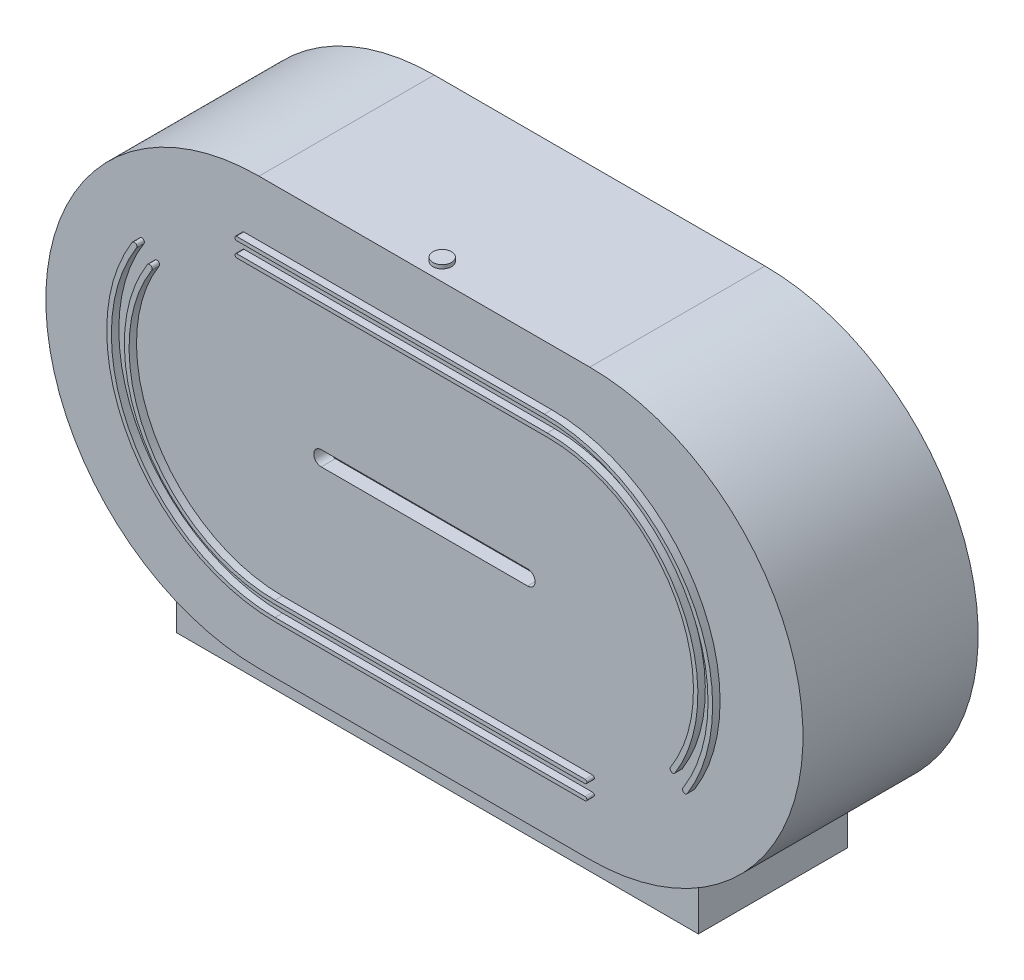
from build123d import *

# Parameters (mm, degrees)
BOSS_EXTRUDE1_DEPTH = 119.38
SKETCH2_W           = 355.6
SKETCH2_H           = 101.6
BOSS_EXTRUDE2_DEPTH = 44.958
CUT_EXTRUDE1_DEPTH  = 9.652
SKETCH4_R           = 6.35
BOSS_EXTRUDE3_DEPTH = 2.54
BOSS_EXTRUDE4_DEPTH = 5.08


with BuildPart() as part:
    # Sketch1 → Boss-Extrude1 (new body)
    with BuildSketch(Plane.XY):
        with BuildLine():
            Line((-76.285439921, 56.800521538), (149.139560079, 56.800521538))
            ThreePointArc((149.139560079, 56.800521538), (294.427560079, -88.487478462), (149.139560079, -233.775478462))
            Line((149.139560079, -233.775478462), (-76.285439921, -233.775478462))
            ThreePointArc((-76.285439921, -233.775478462), (-221.573439921, -88.487478462), (-76.285439921, 56.800521538))
        make_face()
    extrude(amount=BOSS_EXTRUDE1_DEPTH)

    # Sketch2 → Boss-Extrude2 (add)
    with BuildSketch(Plane(origin=(0, -249.650478462, 0), x_dir=(-1, 0, 0), z_dir=(0, -1, 0))):
        with Locations((-36.427060079, -59.69)):
            Rectangle(SKETCH2_W, SKETCH2_H)
    extrude(amount=-BOSS_EXTRUDE2_DEPTH)

    # Sketch3 → Cut-Extrude1 (cut)
    with BuildSketch(Plane.XY.offset(119.38)):
        with BuildLine():
            Line((-33.895177701, -83.407478462), (106.749297859, -83.407478462))
            ThreePointArc((106.749297859, -83.407478462), (111.829297859, -88.487478462), (106.749297859, -93.567478462))
            Line((106.749297859, -93.567478462), (-33.895177701, -93.567478462))
            ThreePointArc((-33.895177701, -93.567478462), (-38.975177701, -88.487478462), (-33.895177701, -83.407478462))
        make_face()
    extrude(amount=-CUT_EXTRUDE1_DEPTH, mode=Mode.SUBTRACT)

    # Sketch4 → Boss-Extrude3 (add)
    with BuildSketch(Plane(origin=(0, 56.800521538, 0), x_dir=(1, 0, 0), z_dir=(0, 1, 0))):
        with Locations((36.427060079, -107.228428284)):
            Circle(SKETCH4_R)
    extrude(amount=BOSS_EXTRUDE3_DEPTH)

    # Sketch5 → Boss-Extrude4 (add)
    with BuildSketch(Plane.XY.offset(119.38)):
        with BuildLine():
            Line((-86.479093302, 18.700521538), (123.251136742, 18.700521538))
            ThreePointArc((123.251136742, 18.700521538), (223.504350955, -40.293834211), (220.612604828, -156.580887552))
            ThreePointArc((220.612604828, -156.580887552), (218.022957646, -157.022271916), (217.893868774, -154.398452419))
            ThreePointArc((217.893868774, -154.398452419), (220.780120028, -41.258888911), (123.251136742, 16.160521538))
            Line((123.251136742, 16.160521538), (-86.479093302, 16.160521538))
            ThreePointArc((-86.479093302, 16.160521538), (-87.749093302, 17.430521538), (-86.479093302, 18.700521538))
        make_face()
        with BuildLine():
            Line((-86.313359517, 8.540521538), (125.193739137, 8.540521538))
            ThreePointArc((125.193739137, 8.540521538), (215.020934696, -44.395432513), (212.23038132, -148.622843039))
            ThreePointArc((212.23038132, -148.622843039), (209.771349214, -149.194111608), (209.219629388, -146.730619796))
            ThreePointArc((209.219629388, -146.730619796), (212.668390329, -45.591104409), (125.608642701, 6.000521538))
            Line((125.608642701, 6.000521538), (-86.313359517, 6.000521538))
            ThreePointArc((-86.313359517, 6.000521538), (-87.583359517, 7.270521538), (-86.313359517, 8.540521538))
        make_face()
        with BuildLine():
            Line((150.962085254, -185.515478462), (-60.295843622, -185.515478462))
            ThreePointArc((-60.295843622, -185.515478462), (-150.123039181, -132.579524411), (-147.332485805, -28.352113885))
            ThreePointArc((-147.332485805, -28.352113885), (-144.876543413, -27.778907884), (-144.317816359, -30.238184654))
            ThreePointArc((-144.317816359, -30.238184654), (-147.45714929, -131.444373213), (-60.295843622, -182.975478462))
            Line((-60.295843622, -182.975478462), (150.962085254, -182.975478462))
            ThreePointArc((150.962085254, -182.975478462), (152.232085254, -184.245478462), (150.962085254, -185.515478462))
        make_face()
        with BuildLine():
            Line((150.962085254, -195.675478462), (-60.295843622, -195.675478462))
            ThreePointArc((-60.295843622, -195.675478462), (-160.549057836, -136.681122713), (-157.657311709, -20.394069372))
            ThreePointArc((-157.657311709, -20.394069372), (-155.067664526, -19.952685009), (-154.938575654, -22.576504505))
            ThreePointArc((-154.938575654, -22.576504505), (-157.824826909, -135.716068014), (-60.295843622, -193.135478462))
            Line((-60.295843622, -193.135478462), (150.962085254, -193.135478462))
            ThreePointArc((150.962085254, -193.135478462), (152.232085254, -194.405478462), (150.962085254, -195.675478462))
        make_face()
    extrude(amount=BOSS_EXTRUDE4_DEPTH)


solid = part.part
